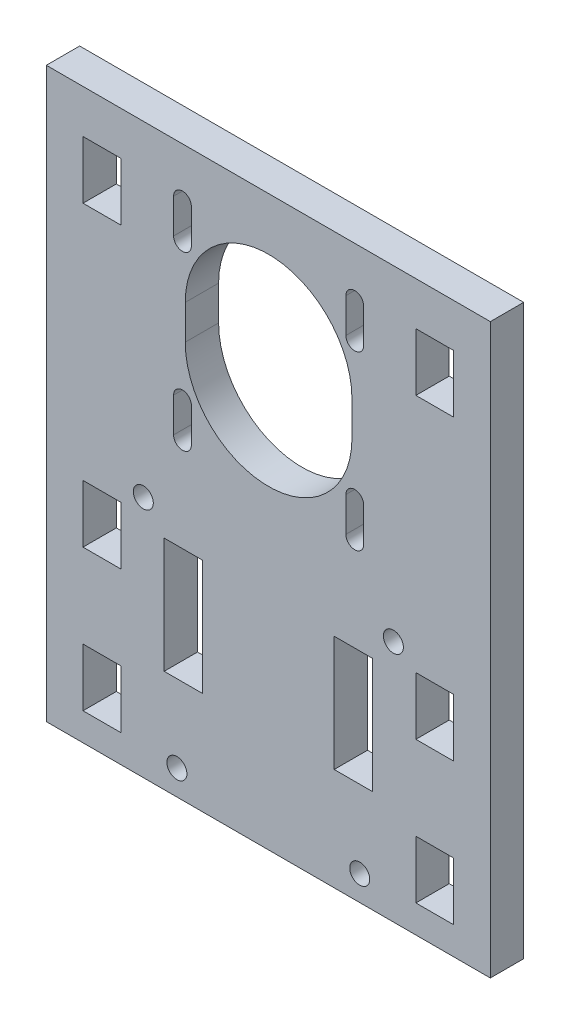
from build123d import *

# Parameters (mm, degrees)
MODEL_W                  = 79.9
MODEL_H                  = 102.298269881
MODEL_R                  = 1.8
MODEL_W_2                = 6.8
MODEL_H_2                = 10.4
MODEL_W_3                = 6.9
MODEL_H_3                = 20.768459162
RESSALTO_EXTRUS_O1_DEPTH = 6


with BuildPart() as part:
    # Model → Ressalto-extrusão1 (new body)
    with BuildSketch(Plane.XY):
        with Locations((69.087325958, 59.378502518)):
            Rectangle(MODEL_W, MODEL_H)
        with Locations((52.637325958, 12.745101048)):
            Circle(MODEL_R, mode=Mode.SUBTRACT)
        with Locations((85.537325958, 12.745101048)):
            Circle(MODEL_R, mode=Mode.SUBTRACT)
        with Locations((91.587325958, 51.927637459)):
            Circle(MODEL_R, mode=Mode.SUBTRACT)
        with Locations((46.587325958, 51.927637459)):
            Circle(MODEL_R, mode=Mode.SUBTRACT)
        with Locations((99.037325958, 97.527637459)):
            Rectangle(MODEL_W_2, MODEL_H_2, mode=Mode.SUBTRACT)
        with Locations((39.137325958, 97.527637459)):
            Rectangle(MODEL_W_2, MODEL_H_2, mode=Mode.SUBTRACT)
        with Locations((99.037325958, 43.927637459)):
            Rectangle(MODEL_W_2, MODEL_H_2, mode=Mode.SUBTRACT)
        with Locations((39.137325958, 18.427637459)):
            Rectangle(MODEL_W_2, MODEL_H_2, mode=Mode.SUBTRACT)
        with Locations((53.787325958, 37.060868969)):
            Rectangle(MODEL_W_3, MODEL_H_3, mode=Mode.SUBTRACT)
        with BuildLine():
            Line((52.037325958, 70.571372091), (52.037325958, 64.371372091))
            ThreePointArc((52.037325958, 64.371372091), (53.637325958, 62.771372091), (55.237325958, 64.371372091))
            Line((55.237325958, 64.371372091), (55.237325958, 70.571372091))
            ThreePointArc((55.237325958, 70.571372091), (53.637325958, 72.171372091), (52.037325958, 70.571372091))
        make_face(mode=Mode.SUBTRACT)
        with Locations((84.387325958, 37.060868969)):
            Rectangle(MODEL_W_3, MODEL_H_3, mode=Mode.SUBTRACT)
        with Locations((99.037325958, 18.427637459)):
            Rectangle(MODEL_W_2, MODEL_H_2, mode=Mode.SUBTRACT)
        with BuildLine():
            Line((86.237325958, 70.571372091), (86.237325958, 64.371372091))
            ThreePointArc((86.237325958, 64.371372091), (84.637325958, 62.771372091), (83.037325958, 64.371372091))
            Line((83.037325958, 64.371372091), (83.037325958, 70.571372091))
            ThreePointArc((83.037325958, 70.571372091), (84.637325958, 72.171372091), (86.237325958, 70.571372091))
        make_face(mode=Mode.SUBTRACT)
        with BuildLine():
            Line((86.237325958, 101.571372091), (86.237325958, 95.371372091))
            ThreePointArc((86.237325958, 95.371372091), (84.637325958, 93.771372091), (83.037325958, 95.371372091))
            Line((83.037325958, 95.371372091), (83.037325958, 101.571372091))
            ThreePointArc((83.037325958, 101.571372091), (84.637325958, 103.171372091), (86.237325958, 101.571372091))
        make_face(mode=Mode.SUBTRACT)
        with Locations((39.137325958, 43.927637459)):
            Rectangle(MODEL_W_2, MODEL_H_2, mode=Mode.SUBTRACT)
        with BuildLine():
            Line((52.037325958, 101.571372091), (52.037325958, 95.371372091))
            ThreePointArc((52.037325958, 95.371372091), (53.637325958, 93.771372091), (55.237325958, 95.371372091))
            Line((55.237325958, 95.371372091), (55.237325958, 101.571372091))
            ThreePointArc((55.237325958, 101.571372091), (53.637325958, 103.171372091), (52.037325958, 101.571372091))
        make_face(mode=Mode.SUBTRACT)
        with BuildLine():
            Line((54.137325958, 86.071372091), (54.137325958, 79.871372091))
            ThreePointArc((54.137325958, 79.871372091), (69.137325958, 64.871372091), (84.137325958, 79.871372091))
            Line((84.137325958, 79.871372091), (84.137325958, 86.071372091))
            ThreePointArc((84.137325958, 86.071372091), (69.137325958, 101.071372091), (54.137325958, 86.071372091))
        make_face(mode=Mode.SUBTRACT)
    extrude(amount=RESSALTO_EXTRUS_O1_DEPTH)


solid = part.part
